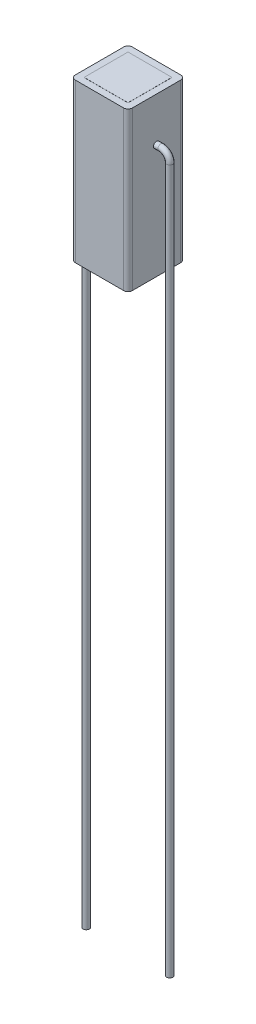
from build123d import *

# Parameters (mm, degrees)
SKETCH1_W                = 6.5
SKETCH1_H                = 6.5
BOSS_EXTRUDE1_DEPTH      = 18
SKETCH2_W                = 5
SKETCH2_H                = 5
BOSS_EXTRUDE2_DEPTH      = 18.01
BOSS_EXTRUDE2_DEPTH_BACK = 0.01
SWEEP2_PROFILE_R         = 0.35
FILLET2_R                = 0.5


with BuildPart() as part:
    # Sketch1 → Boss-Extrude1 (new body)
    with BuildSketch(Plane(origin=(0, 0, 0), x_dir=(1, 0, 0), z_dir=(0, 1, 0))):
        Rectangle(SKETCH1_W, SKETCH1_H)
    boss_extrude1 = extrude(amount=BOSS_EXTRUDE1_DEPTH)

    # Sketch2 → Boss-Extrude2 (add, two sides)
    with BuildSketch(Plane(origin=(0, 0, 0), x_dir=(1, 0, 0), z_dir=(0, 1, 0))) as boss_extrude2_sk:
        Rectangle(SKETCH2_W, SKETCH2_H)
    extrude(amount=BOSS_EXTRUDE2_DEPTH)
    extrude(boss_extrude2_sk.sketch, amount=-BOSS_EXTRUDE2_DEPTH_BACK)

    # Sweep2: sweep along a path in Sketch4
    with BuildLine(Plane.XY) as sweep2_path:
        Line((3.2, 13), (3.25, 13))
        Line((3.25, 13), (3.75, 13))
        ThreePointArc((3.75, 13), (4.457106781, 12.707106781), (4.75, 12))
        Line((4.75, 12), (4.75, -68.117103267))
    # Sweep2 profile (on start of the path) → Sweep2 (sweep)
    with BuildSketch(Plane(origin=(3.2, 13, 0), x_dir=(0, 0, 1), z_dir=(1, 0, 0))):
        Circle(SWEEP2_PROFILE_R)
    sweep2 = sweep(path=sweep2_path.line)

    # Mirror1: Boss-Extrude1, Sweep2 across plane
    add(boss_extrude1.mirror(Plane(origin=(0, 0, 0), x_dir=(0, 0, 1), z_dir=(1, 0, 0))))
    add(sweep2.mirror(Plane(origin=(0, 0, 0), x_dir=(0, 0, 1), z_dir=(1, 0, 0))))

    # Fillet2
    fillet2_edges = [part.edges().sort_by_distance(p)[0] for p in [
        (3.25, 9, 3.25),
        (-3.25, 9, 3.25),
        (-3.25, 9, -3.25),
        (3.25, 9, -3.25),
    ]]
    fillet(fillet2_edges, radius=FILLET2_R)


solid = part.part
